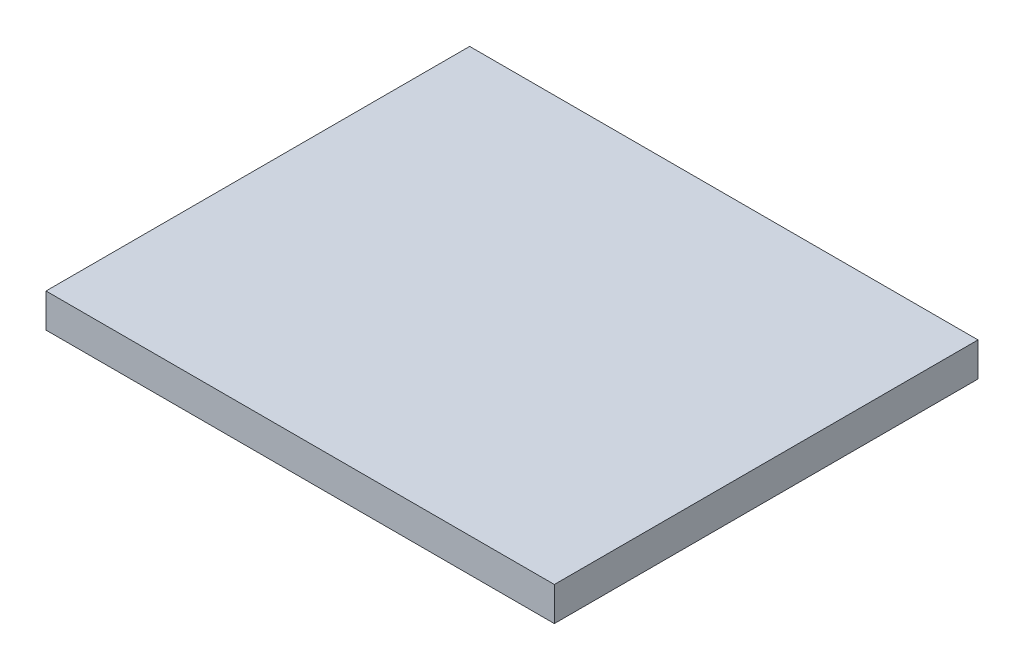
from build123d import *

# Parameters (mm, degrees)
SKETCH_1_W      = 25
SKETCH_1_H      = 2
EXTRUDE_1_DEPTH = 30


with BuildPart() as part:
    # 草图1 → 凸台-拉伸1 (new body)
    with BuildSketch(Plane(origin=(0, 0, 0), x_dir=(0, 0, -1), z_dir=(1, 0, 0))):
        Rectangle(SKETCH_1_W, SKETCH_1_H)
    extrude(amount=EXTRUDE_1_DEPTH)


solid = part.part
